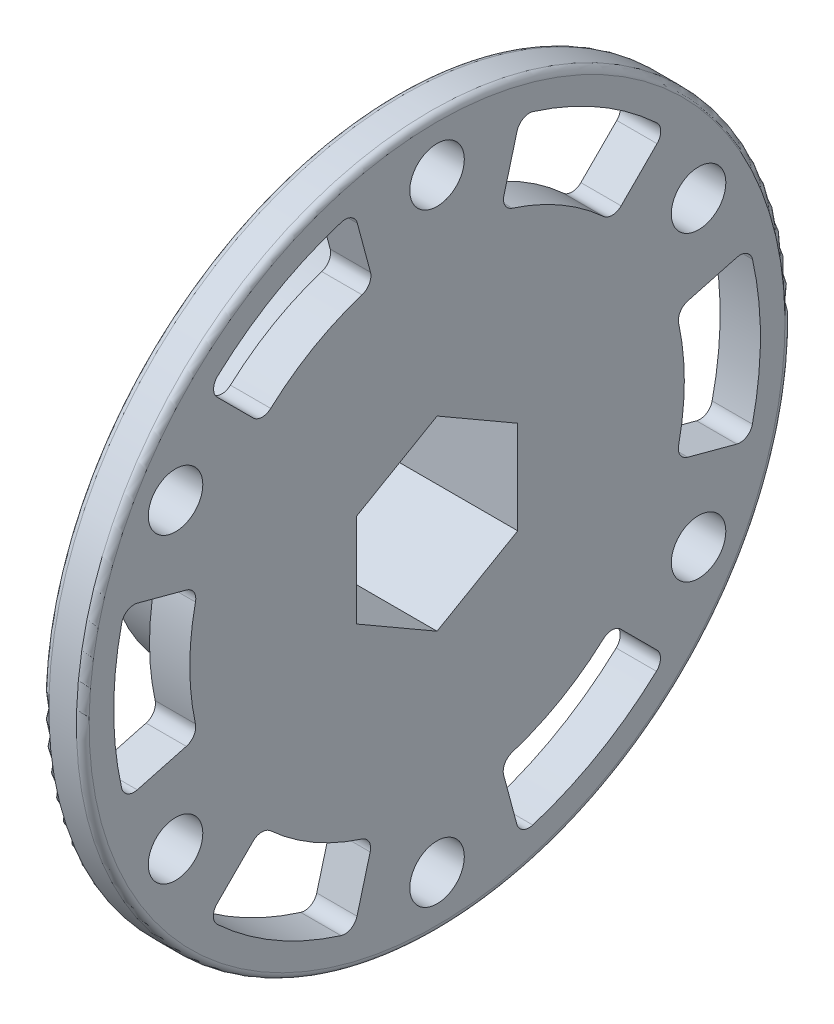
from build123d import *

# Parameters (mm, degrees)
SKETCH1_W                      = 3.175
SKETCH1_H                      = 27.94
CUT_EXTRUDE1_DEPTH             = 4.175
CUT_EXTRUDE2_DEPTH             = 4.175
CUT_EXTRUDE3_DEPTH             = 4.175
CUT_EXTRUDE4_DEPTH             = 4.175
CUT_EXTRUDE5_DEPTH             = 4.175
CUT_EXTRUDE6_DEPTH             = 4.175
SKETCH8_R                      = 14.294919975
BOSS_EXTRUDE1_DEPTH            = 9.525
CUT_EXTRUDE7_DEPTH             = 13.7
F_4_3_4_3_DIAMETER_HOLE1_D     = 4.3
F_4_3_4_3_DIAMETER_HOLE1_DEPTH = 12.7
CHAMFER1_SIZE                  = 1
FILLET1_R                      = 0.5
FILLET2_R                      = 1
FILLET3_R                      = 1.27


with BuildPart() as part:
    # Sketch1 → Revolve1 (revolve)
    with BuildSketch(Plane(origin=(0, 0, 0), x_dir=(-1, 0, 0), z_dir=(0, 0, -1))):
        with Locations((-11.1125, 13.97)):
            Rectangle(SKETCH1_W, SKETCH1_H)
    revolve(axis=Axis((12.7, 0, 0), (-1, 0, 0)))

    # Sketch2 → Cut-Extrude1 (cut, through all)
    with BuildSketch(Plane.ZY.offset(-9.525)):
        with BuildLine():
            Line((-13.806531048, -13.770610024), (-18.049174487, -18.013253463))
            ThreePointArc((-18.049174487, -18.013253463), (-12.738999884, -22.089995065), (-6.550803522, -24.644207701))
            Line((-6.550803522, -24.644207701), (-4.997885221, -18.848637704))
            ThreePointArc((-4.997885221, -18.848637704), (-9.738999389, -16.893841804), (-13.806531048, -13.770610024))
        make_face()
    extrude(amount=-CUT_EXTRUDE1_DEPTH, mode=Mode.SUBTRACT)

    # Sketch3 → Cut-Extrude2 (cut, through all)
    with BuildSketch(Plane.ZY.offset(-9.525)):
        with BuildLine():
            Line((5.022432582, -18.842111637), (6.57534786, -24.637670355))
            ThreePointArc((6.57534786, -24.637670355), (12.760996954, -22.077295051), (18.067108165, -17.995266116))
            Line((18.067108165, -17.995266116), (13.824456468, -13.752614419))
            ThreePointArc((13.824456468, -13.752614419), (9.760996476, -16.88114178), (5.022432582, -18.842111637))
        make_face()
    extrude(amount=-CUT_EXTRUDE2_DEPTH, mode=Mode.SUBTRACT)

    # Sketch4 → Cut-Extrude3 (cut, through all)
    with BuildSketch(Plane.ZY.offset(-9.525)):
        with BuildLine():
            Line((18.82896363, -5.071501614), (24.624522347, -6.624416892))
            ThreePointArc((24.624522347, -6.624416892), (25.499996837, 0.012700014), (24.617911686, 6.648941586))
            Line((24.617911686, 6.648941586), (18.822341689, 5.096023285))
            ThreePointArc((18.822341689, 5.096023285), (19.499995864, 0.012700024), (18.82896363, -5.071501614))
        make_face()
    extrude(amount=-CUT_EXTRUDE3_DEPTH, mode=Mode.SUBTRACT)

    # Sketch5 → Cut-Extrude4 (cut, through all)
    with BuildSketch(Plane.ZY.offset(-9.525)):
        with BuildLine():
            Line((13.806531048, 13.770610024), (18.049174487, 18.013253463))
            ThreePointArc((18.049174487, 18.013253463), (12.738999884, 22.089995065), (6.550803522, 24.644207701))
            Line((6.550803522, 24.644207701), (4.997885221, 18.848637704))
            ThreePointArc((4.997885221, 18.848637704), (9.738999389, 16.893841804), (13.806531048, 13.770610024))
        make_face()
    extrude(amount=-CUT_EXTRUDE4_DEPTH, mode=Mode.SUBTRACT)

    # Sketch6 → Cut-Extrude5 (cut, through all)
    with BuildSketch(Plane.ZY.offset(-9.525)):
        with BuildLine():
            Line((-24.617911686, -6.648941586), (-18.822341689, -5.096023285))
            ThreePointArc((-18.822341689, -5.096023285), (-19.499995864, -0.012700024), (-18.82896363, 5.071501614))
            Line((-18.82896363, 5.071501614), (-24.624522347, 6.624416892))
            ThreePointArc((-24.624522347, 6.624416892), (-25.499996837, -0.012700014), (-24.617911686, -6.648941586))
        make_face()
    extrude(amount=-CUT_EXTRUDE5_DEPTH, mode=Mode.SUBTRACT)

    # Sketch7 → Cut-Extrude6 (cut, through all)
    with BuildSketch(Plane(origin=(12.7, 0, 0), x_dir=(0, 0, -1), z_dir=(1, 0, 0))):
        with BuildLine():
            Line((6.57534786, 24.637670355), (5.022432582, 18.842111637))
            ThreePointArc((5.022432582, 18.842111637), (9.760996476, 16.88114178), (13.824456468, 13.752614419))
            Line((13.824456468, 13.752614419), (18.067108165, 17.995266116))
            ThreePointArc((18.067108165, 17.995266116), (12.760996954, 22.077295051), (6.57534786, 24.637670355))
        make_face()
    extrude(amount=-CUT_EXTRUDE6_DEPTH, mode=Mode.SUBTRACT)

    # Sketch8 → Boss-Extrude1 (add)
    with BuildSketch(Plane.ZY.offset(-9.525)):
        Circle(SKETCH8_R)
    extrude(amount=BOSS_EXTRUDE1_DEPTH)

    # Sketch9 → Cut-Extrude7 (cut, through all)
    with BuildSketch(Plane(origin=(12.7, 0, 0), x_dir=(0, 0, -1), z_dir=(1, 0, 0))):
        Polygon((-6.3627, 3.673506558), (-6.3627, -3.673506558), (0, -7.347013116), (6.3627, -3.673506558), (6.3627, 3.673506558), (0, 7.347013116), align=None)
    extrude(amount=-CUT_EXTRUDE7_DEPTH, mode=Mode.SUBTRACT)

    # Ø4.3 (4.3) Diameter Hole1
    with Locations(Plane(origin=(12.7, 0, 0), x_dir=(0, 0, -1), z_dir=(1, 0, 0))):
        with Locations((20.622229928, 11.90625), (20.622229928, -11.90625), (0, -23.8125), (-20.622229928, -11.90625), (-20.622229928, 11.90625), (0, 23.8125)):
            Hole(F_4_3_4_3_DIAMETER_HOLE1_D / 2, depth=F_4_3_4_3_DIAMETER_HOLE1_DEPTH)

    # Chamfer1
    chamfer1_edges = [part.edges().sort_by_distance(p)[0] for p in [
        (0, 0, -14.294919975),
    ]]
    chamfer(chamfer1_edges, length=CHAMFER1_SIZE)

    # Fillet1
    fillet1_edges = [part.edges().sort_by_distance(p)[0] for p in [
        (9.525, -27.94, 0),
        (12.7, -27.94, 0),
    ]]
    fillet(fillet1_edges, radius=FILLET1_R)

    # Fillet2
    fillet2_edges = [part.edges().sort_by_distance(p)[0] for p in [
        (11.1125, -13.770610024, -13.806531048),
        (11.1125, -18.848637704, -4.997885221),
        (11.1125, -24.644207701, -6.550803522),
        (11.1125, -18.013253463, -18.049174487),
        (11.1125, -18.842111637, 5.022432582),
        (11.1125, -13.752614419, 13.824456468),
        (11.1125, -17.995266116, 18.067108165),
        (11.1125, -24.637670355, 6.57534786),
        (11.1125, -5.071501614, 18.82896363),
        (11.1125, 5.096023285, 18.822341689),
        (11.1125, 6.648941586, 24.617911686),
        (11.1125, -6.624416892, 24.624522347),
        (11.1125, 13.770610024, 13.806531048),
        (11.1125, 18.848637704, 4.997885221),
        (11.1125, 24.644207701, 6.550803522),
        (11.1125, 18.013253463, 18.049174487),
        (11.1125, -6.648941586, -24.617911686),
        (11.1125, 6.624416892, -24.624522347),
        (11.1125, 5.071501614, -18.82896363),
        (11.1125, -5.096023285, -18.822341689),
        (11.1125, 24.637670355, -6.57534786),
        (11.1125, 17.995266116, -18.067108165),
        (11.1125, 13.752614419, -13.824456468),
        (11.1125, 18.842111637, -5.022432582),
    ]]
    fillet(fillet2_edges, radius=FILLET2_R)

    # Fillet3
    fillet3_edges = [part.edges().sort_by_distance(p)[0] for p in [
        (9.525, 0, -14.294919975),
    ]]
    fillet(fillet3_edges, radius=FILLET3_R)


solid = part.part
